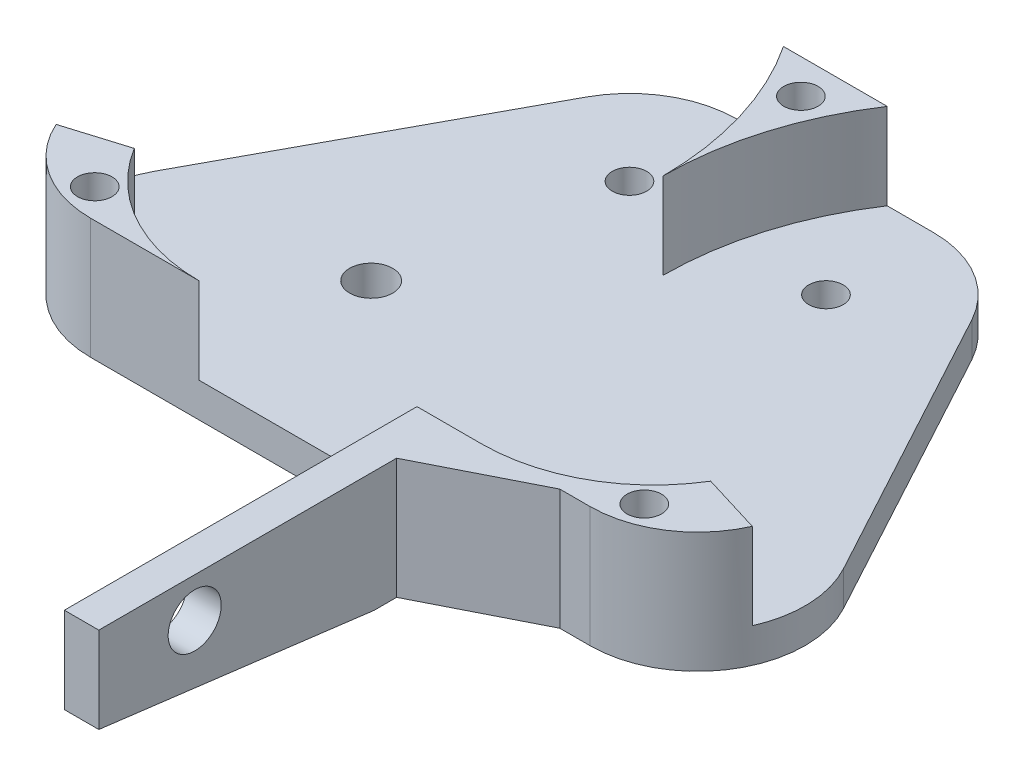
from build123d import *

# Parameters (mm, degrees)
SKETCH1_R           = 2.5
SKETCH1_R_2         = 2
BOSS_EXTRUDE1_DEPTH = 4
BOSS_EXTRUDE2_START = 4
SKETCH1_3_R         = 2
BOSS_EXTRUDE2_DEPTH = 10
BOSS_EXTRUDE4_START = 8.9154
SKETCH4_R           = 3.081113055
BOSS_EXTRUDE4_DEPTH = 4
BOSS_EXTRUDE5_DEPTH = 14


with BuildPart() as part:
    # Sketch1 → Boss-Extrude1 (new body)
    with BuildSketch(Plane(origin=(0, 0, 0), x_dir=(1, 0, 0), z_dir=(0, 1, 0))):
        with BuildLine():
            Line((-11.41, 37.5), (11.41, 37.5))
            ThreePointArc((11.41, 37.5), (17.8088531, 35.73800163), (22.403743203, 30.948748641))
            Line((22.403743203, 30.948748641), (39.989594287, -1.551251359))
            ThreePointArc((39.989594287, -1.551251359), (39.733852714, -13.8988531), (28.995851084, -20))
            Line((28.995851084, -20), (-28.995851084, -20))
            ThreePointArc((-28.995851084, -20), (-39.733852714, -13.8988531), (-39.989594287, -1.551251359))
            Line((-39.989594287, -1.551251359), (-22.403743203, 30.948748641))
            ThreePointArc((-22.403743203, 30.948748641), (-17.8088531, 35.73800163), (-11.41, 37.5))
        make_face()
        with Locations((-16.41, 0)):
            Circle(SKETCH1_R, mode=Mode.SUBTRACT)
        with Locations((-11.41, 25)):
            Circle(SKETCH1_R_2, mode=Mode.SUBTRACT)
        with Locations((11.41, 25)):
            Circle(SKETCH1_R_2, mode=Mode.SUBTRACT)
        with Locations((0, 33.5)):
            Circle(SKETCH1_R_2, mode=Mode.SUBTRACT)
        with Locations((31.91, -16.6)):
            Circle(SKETCH1_R_2, mode=Mode.SUBTRACT)
        with Locations((-31.91, -16.6)):
            Circle(SKETCH1_R_2, mode=Mode.SUBTRACT)
    extrude(amount=BOSS_EXTRUDE1_DEPTH)

    # Sketch1_3 → Boss-Extrude2 (add)
    with BuildSketch(Plane(origin=(0, 0, 0), x_dir=(1, 0, 0), z_dir=(0, 1, 0)).offset(BOSS_EXTRUDE2_START)):
        with BuildLine():
            ThreePointArc((-16.41, -20), (-26.18584907, -17.448002034), (-33.466903445, -10.443277496))
            Line((-33.466903445, -10.443277496), (-40.421677434, -12.569565287))
            ThreePointArc((-40.421677434, -12.569565287), (-35.810557017, -17.979016321), (-28.995851084, -20))
            Line((-28.995851084, -20), (-16.41, -20))
        make_face()
        with Locations((-31.91, -16.6)):
            Circle(SKETCH1_3_R, mode=Mode.SUBTRACT)
        with BuildLine():
            ThreePointArc((33.466903445, -10.443277496), (26.18584907, -17.448002034), (16.41, -20))
            Line((16.41, -20), (28.995851084, -20))
            ThreePointArc((28.995851084, -20), (35.810557017, -17.979016321), (40.421677434, -12.569565287))
            Line((40.421677434, -12.569565287), (33.466903445, -10.443277496))
        make_face()
        with Locations((31.91, -16.6)):
            Circle(SKETCH1_3_R, mode=Mode.SUBTRACT)
        with BuildLine():
            Line((6.025107723, 37.5), (-6.025107723, 37.5))
            ThreePointArc((-6.025107723, 37.5), (-1.538984336, 27.943920757), (0, 17.5))
            ThreePointArc((0, 17.5), (1.538984336, 27.943920757), (6.025107723, 37.5))
        make_face()
        with Locations((0, 33.5)):
            Circle(SKETCH1_3_R, mode=Mode.SUBTRACT)
    extrude(amount=BOSS_EXTRUDE2_DEPTH)

    # Sketch4 → Boss-Extrude4 (add)
    with BuildSketch(Plane(origin=(0, 0, 0), x_dir=(0, 0, -1), z_dir=(1, 0, 0)).offset(BOSS_EXTRUDE4_START)):
        Polygon((-20, 0), (-28.99333943, 0), (-60.952260121, 4), (-60.952260121, 14), (-20, 14), align=None)
        with Locations((-49.816366974, 9.411784345)):
            Circle(SKETCH4_R, mode=Mode.SUBTRACT)
    extrude(amount=BOSS_EXTRUDE4_DEPTH)

    # Sketch5 → Boss-Extrude5 (add)
    with BuildSketch(Plane(origin=(0, 14, 0), x_dir=(1, 0, 0), z_dir=(0, 1, 0))):
        Polygon((12.9154, -20), (12.9154, -26.368170387), (25.501140128, -20), align=None)
    extrude(amount=-BOSS_EXTRUDE5_DEPTH)


solid = part.part
